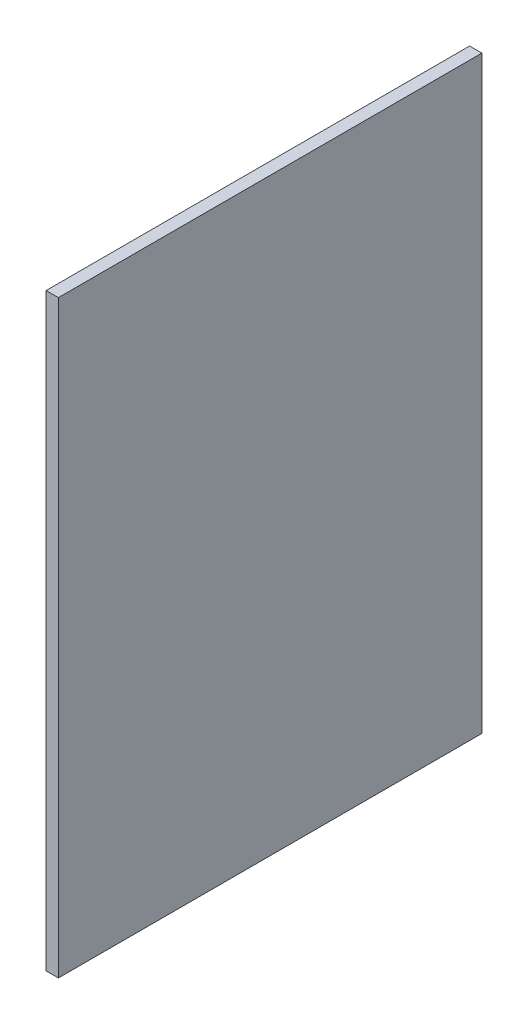
from build123d import *

# Parameters (mm, degrees)
SKETCH1_W           = 876.3
SKETCH1_H           = 1219.2
BOSS_EXTRUDE1_DEPTH = 25.4


with BuildPart() as part:
    # Sketch1 → Boss-Extrude1 (new body)
    with BuildSketch(Plane(origin=(0, 0, 0), x_dir=(0, 0, -1), z_dir=(1, 0, 0))):
        with Locations((438.15, -609.6)):
            Rectangle(SKETCH1_W, SKETCH1_H)
    extrude(amount=BOSS_EXTRUDE1_DEPTH)


solid = part.part
